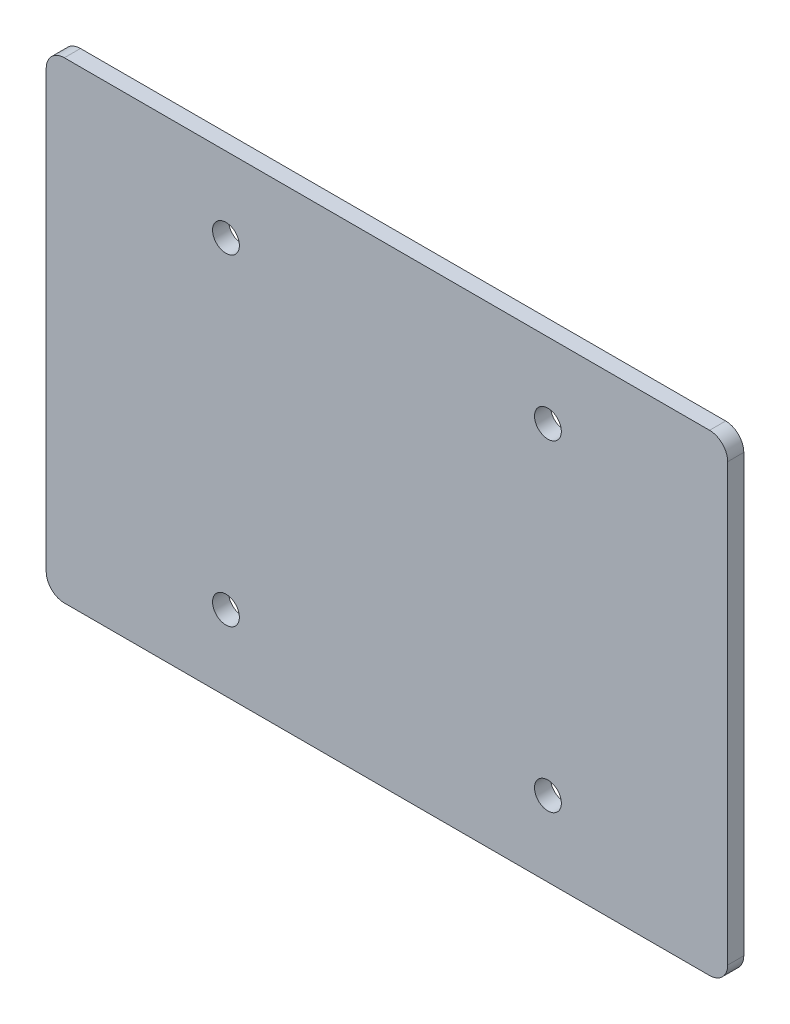
from build123d import *

# Parameters (mm, degrees)
SKETCH2_W           = 127
SKETCH2_H           = 88
BOSS_EXTRUDE1_DEPTH = 3
FILLET1_R           = 3.38
SKETCH3_R           = 2.5
CUT_EXTRUDE1_DEPTH  = 4


with BuildPart() as part:
    # Sketch2 → Boss-Extrude1 (new body)
    with BuildSketch(Plane.XY):
        Rectangle(SKETCH2_W, SKETCH2_H)
    extrude(amount=BOSS_EXTRUDE1_DEPTH)

    # Fillet1
    fillet1_edges = [part.edges().sort_by_distance(p)[0] for p in [
        (63.5, -44, 1.5),
        (-63.5, -44, 1.5),
        (-63.5, 44, 1.5),
        (63.5, 44, 1.5),
    ]]
    fillet(fillet1_edges, radius=FILLET1_R)

    # Sketch3 → Cut-Extrude1 (cut, through all)
    with BuildSketch(Plane(origin=(0, 0, 0), x_dir=(-1, 0, 0), z_dir=(0, 0, -1))):
        with Locations((-30, -30)):
            Circle(SKETCH3_R)
        with Locations((-30, 30)):
            Circle(SKETCH3_R)
        with Locations((30, 30)):
            Circle(SKETCH3_R)
        with Locations((30, -30)):
            Circle(SKETCH3_R)
    extrude(amount=-CUT_EXTRUDE1_DEPTH, mode=Mode.SUBTRACT)


solid = part.part
